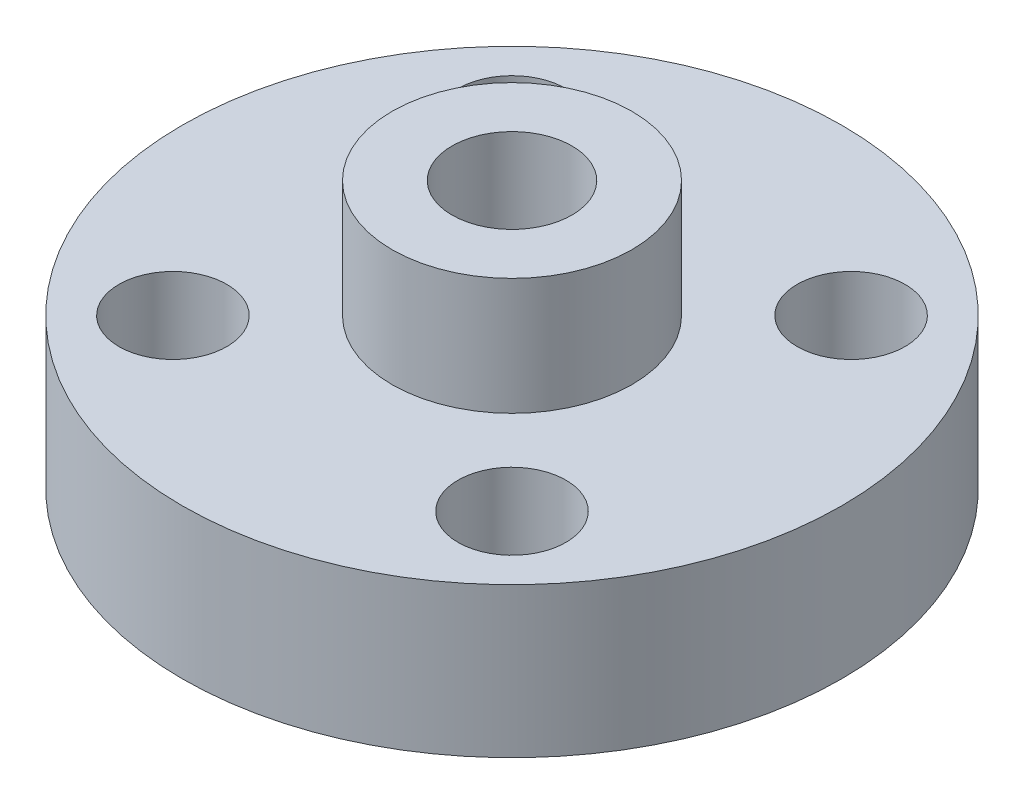
from build123d import *

# Parameters (mm, degrees)
SKETCH_1_R          = 11
EXTRUDE_1_DEPTH     = 5
SKETCH_2_R          = 4
EXTRUDE_2_DEPTH     = 3.9
SKETCH_3_R          = 1.8
CUT_EXTRUDE_1_DEPTH = 6
SKETCH_4_R          = 2
CUT_EXTRUDE_2_DEPTH = 9.9
SKETCH_6_R          = 1.25
CUT_EXTRUDE_3_DEPTH = 13


with BuildPart() as part:
    # 스케치1 → 보스-돌출1 (new body)
    with BuildSketch(Plane(origin=(0, 0, 0), x_dir=(1, 0, 0), z_dir=(0, 1, 0))):
        Circle(SKETCH_1_R)
    extrude(amount=EXTRUDE_1_DEPTH)

    # 스케치2 → 보스-돌출2 (add)
    with BuildSketch(Plane(origin=(0, 5, 0), x_dir=(1, 0, 0), z_dir=(0, 1, 0))):
        Circle(SKETCH_2_R)
    extrude(amount=EXTRUDE_2_DEPTH)

    # 스케치3 → 컷-돌출1 (cut, through all)
    with BuildSketch(Plane(origin=(0, 5, 0), x_dir=(1, 0, 0), z_dir=(0, 1, 0))):
        with Locations((5.656854249, 5.656854249)):
            Circle(SKETCH_3_R)
        with Locations((-5.656854249, -5.656854249)):
            Circle(SKETCH_3_R)
        with Locations((-5.656854249, 5.656854249)):
            Circle(SKETCH_3_R)
        with Locations((5.656854249, -5.656854249)):
            Circle(SKETCH_3_R)
    extrude(amount=-CUT_EXTRUDE_1_DEPTH, mode=Mode.SUBTRACT)

    # 스케치4 → 컷-돌출2 (cut, through all)
    with BuildSketch(Plane(origin=(0, 8.9, 0), x_dir=(1, 0, 0), z_dir=(0, 1, 0))):
        Circle(SKETCH_4_R)
    extrude(amount=-CUT_EXTRUDE_2_DEPTH, mode=Mode.SUBTRACT)

    # 스케치6 → 컷-돌출3 (cut)
    with BuildSketch(Plane.XY):
        with Locations((0, 2.5)):
            Circle(SKETCH_6_R)
    extrude(amount=-CUT_EXTRUDE_3_DEPTH, mode=Mode.SUBTRACT)


solid = part.part
